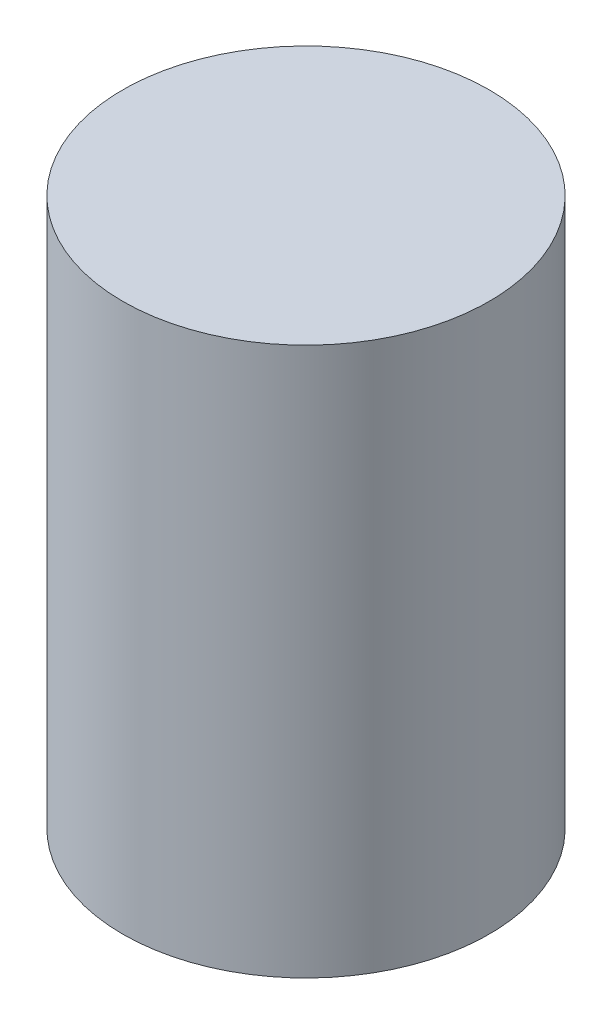
from build123d import *

# Parameters (mm, degrees)
SKETCH1_R           = 22.2504
BOSS_EXTRUDE1_DEPTH = 66.548


with BuildPart() as part:
    # Sketch1 → Boss-Extrude1 (new body)
    with BuildSketch(Plane(origin=(0, 0, 0), x_dir=(1, 0, 0), z_dir=(0, 1, 0))):
        Circle(SKETCH1_R)
    extrude(amount=BOSS_EXTRUDE1_DEPTH)


solid = part.part
